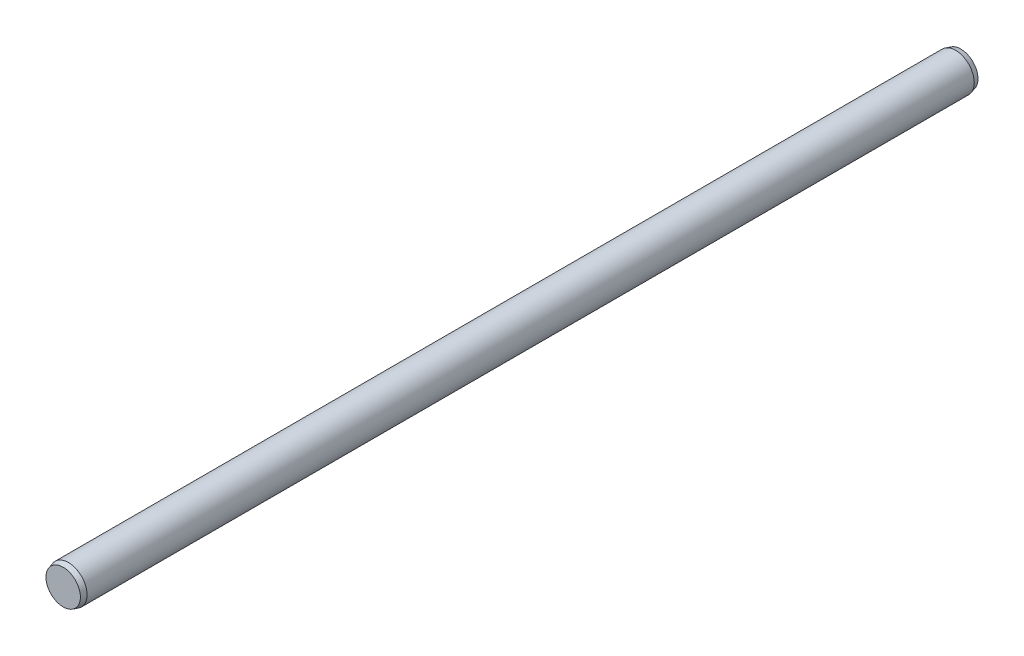
from build123d import *


with BuildPart() as part:
    # Sketch3 → Revolve1 (revolve)
    with BuildSketch(Plane(origin=(0, 0, 0), x_dir=(0, 0, -1), z_dir=(1, 0, 0))):
        Polygon((-76.2, 0), (76.2, 0), (76.2, 2.921), (75.314196731, 3.175), (-75.314196731, 3.175), (-76.2, 2.921), align=None)
    revolve(axis=Axis((0, 0, 76.2), (0, 0, -1)))


solid = part.part
